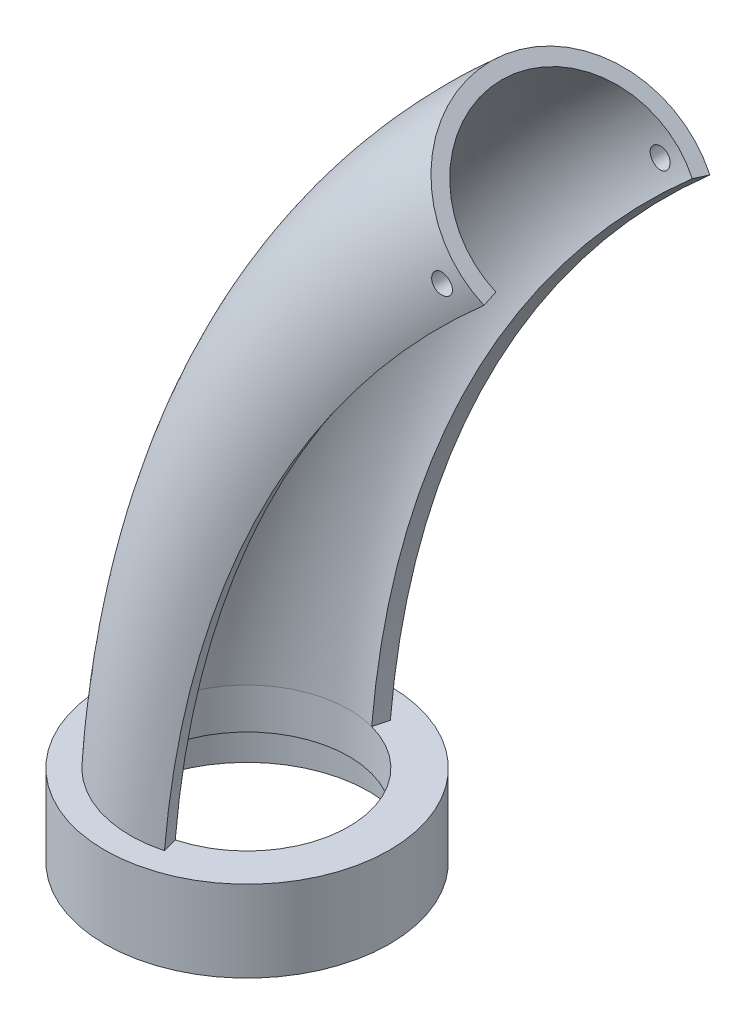
from build123d import *

# Parameters (mm, degrees)
SKETCH2_R               = 88.9
SKETCH2_R_2             = 63.5
BOSS_EXTRUDE1_DEPTH     = 50.8
SKETCH2_4_R             = 76.2
SKETCH2_4_R_2           = 63.5
CUT_EXTRUDE1_DEPTH      = 25.4
CUT_EXTRUDE2_DEPTH      = 562.204013319
CUT_EXTRUDE2_DEPTH_BACK = 562.204013319
SKETCH5_R               = 6.35


with BuildPart() as part:
    # Sketch2 → Boss-Extrude1 (new body)
    with BuildSketch(Plane(origin=(0, 0, 0), x_dir=(1, 0, 0), z_dir=(0, 1, 0))):
        Circle(SKETCH2_R)
        Circle(SKETCH2_R_2, mode=Mode.SUBTRACT)
    extrude(amount=BOSS_EXTRUDE1_DEPTH)

    # Sketch2_4 → Cut-Extrude1 (cut)
    with BuildSketch(Plane(origin=(0, 0, 0), x_dir=(1, 0, 0), z_dir=(0, 1, 0))):
        Circle(SKETCH2_4_R)
        Circle(SKETCH2_4_R_2, mode=Mode.SUBTRACT)
    extrude(amount=CUT_EXTRUDE1_DEPTH, mode=Mode.SUBTRACT)

    # Sweep1: sweep along a path in Sketch3
    with BuildLine(Plane.XY) as sweep1_path:
        ThreePointArc((2.12035425, 50.8), (64.93047334, 273.764984481), (206.387500194, 457.2))
    # Sketch4 → Sweep1 (sweep)
    with BuildSketch(Plane(origin=(0, 50.8, 0), x_dir=(1, 0, 0), z_dir=(0, 1, 0))):
        with BuildLine():
            Line((16.435009364, 61.336289969), (18.900260769, 70.536733465))
            ThreePointArc((18.900260769, 70.536733465), (-73.025, 0), (18.900260769, -70.536733465))
            Line((18.900260769, -70.536733465), (16.435009364, -61.336289969))
            ThreePointArc((16.435009364, -61.336289969), (-63.5, 0), (16.435009364, 61.336289969))
        make_face()
    sweep(path=sweep1_path.line)

    # Sketch5 → Cut-Extrude2 (cut, two sides: drawn at the far end of the back side and taken through both)
    with BuildSketch(Plane.XY.offset(-CUT_EXTRUDE2_DEPTH_BACK)):
        with Locations((194.61898253, 446.545535349)):
            Circle(SKETCH5_R)
    extrude(amount=CUT_EXTRUDE2_DEPTH + CUT_EXTRUDE2_DEPTH_BACK, mode=Mode.SUBTRACT)


solid = part.part
